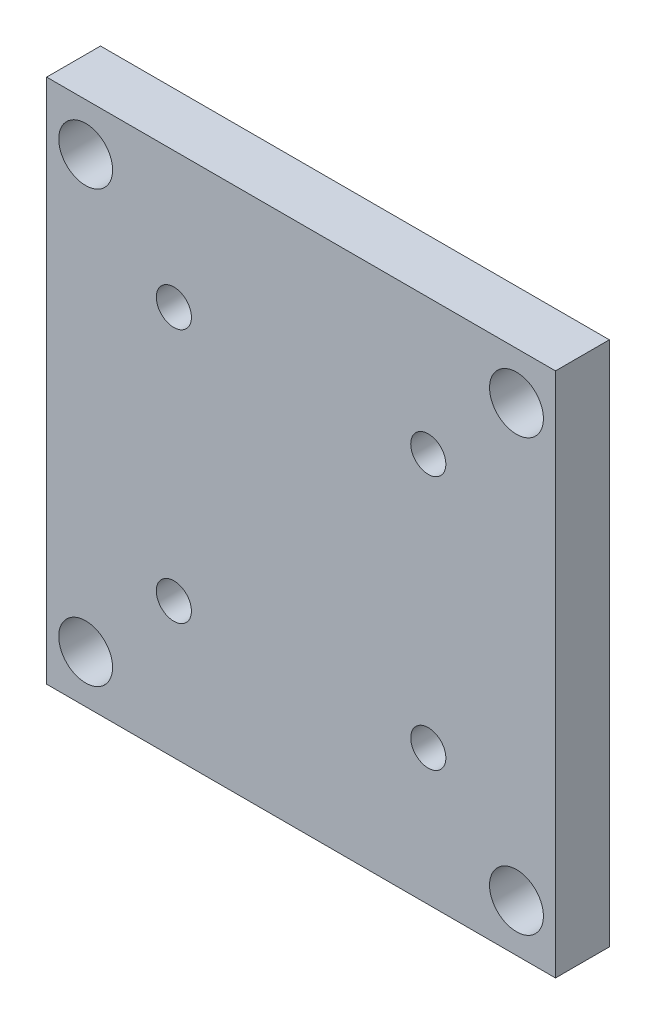
from build123d import *

# Parameters (mm, degrees)
SKETCH1_W           = 60
SKETCH1_H           = 62
SKETCH1_R           = 3.175
SKETCH1_R_2         = 2.071
BOSS_EXTRUDE1_DEPTH = 6.35


with BuildPart() as part:
    # Sketch1 → Boss-Extrude1 (new body)
    with BuildSketch(Plane.XY):
        Rectangle(SKETCH1_W, SKETCH1_H)
        with Locations((25.4, 25.4)):
            Circle(SKETCH1_R, mode=Mode.SUBTRACT)
        with Locations((-25.4, 25.4)):
            Circle(SKETCH1_R, mode=Mode.SUBTRACT)
        with Locations((25.4, -25.4)):
            Circle(SKETCH1_R, mode=Mode.SUBTRACT)
        with Locations((-25.4, -25.4)):
            Circle(SKETCH1_R, mode=Mode.SUBTRACT)
        with Locations((-15, 15)):
            Circle(SKETCH1_R_2, mode=Mode.SUBTRACT)
        with Locations((-15, -15)):
            Circle(SKETCH1_R_2, mode=Mode.SUBTRACT)
        with Locations((15, -15)):
            Circle(SKETCH1_R_2, mode=Mode.SUBTRACT)
        with Locations((15, 15)):
            Circle(SKETCH1_R_2, mode=Mode.SUBTRACT)
    extrude(amount=BOSS_EXTRUDE1_DEPTH)


solid = part.part
